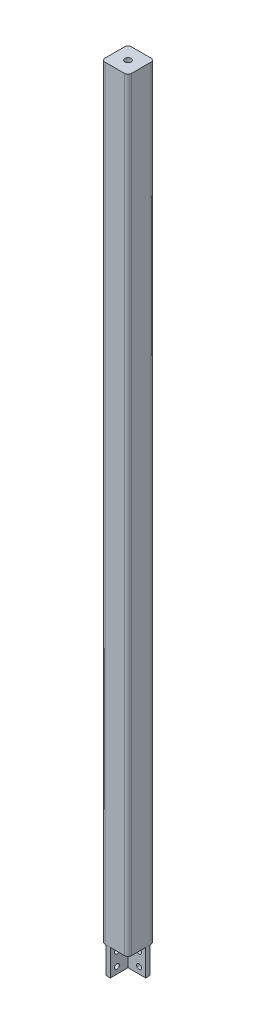
from build123d import *

# Parameters (mm, degrees)
F_60_X_60_X_4_0_1_DEPTH          = 1720
EXTRUDE_1_DEPTH                  = 10
HOLE_WIZARD_M16_1_D              = 14
EXTRUDE_4_DEPTH                  = 10
EXTRUDE_5_DEPTH                  = 60
SKETCH_22_W                      = 5.5
SKETCH_22_H                      = 50
HOLE_WIZARD_11_0_11_1_AT_2_COUNT = 2
HOLE_WIZARD_11_0_11_1_AT_2_PITCH = 30
SKETCH_24_W                      = 5.5
SKETCH_24_H                      = 20
HOLE_WIZARD_11_0_11_2_AT_2_COUNT = 2
HOLE_WIZARD_11_0_11_2_AT_2_PITCH = 30


with BuildPart() as part:
    # Sketch1 → 方管 60 X 60 X 4.0(1) (new body)
    with BuildSketch(Plane.XZ.offset(-1720)):
        with BuildLine():
            Line((-22, -30), (22, -30))
            ThreePointArc((22, -30), (27.656854249, -27.656854249), (30, -22))
            Line((30, -22), (30, 22))
            ThreePointArc((30, 22), (27.656854249, 27.656854249), (22, 30))
            Line((22, 30), (-22, 30))
            ThreePointArc((-22, 30), (-27.656854249, 27.656854249), (-30, 22))
            Line((-30, 22), (-30, -22))
            ThreePointArc((-30, -22), (-27.656854249, -27.656854249), (-22, -30))
        make_face()
        with BuildLine():
            Line((-22, -26), (22, -26))
            ThreePointArc((22, -26), (24.828427125, -24.828427125), (26, -22))
            Line((26, -22), (26, 22))
            ThreePointArc((26, 22), (24.828427125, 24.828427125), (22, 26))
            Line((22, 26), (-22, 26))
            ThreePointArc((-22, 26), (-24.828427125, 24.828427125), (-26, 22))
            Line((-26, 22), (-26, -22))
            ThreePointArc((-26, -22), (-24.828427125, -24.828427125), (-22, -26))
        make_face(mode=Mode.SUBTRACT)
    extrude(amount=F_60_X_60_X_4_0_1_DEPTH)

    # 草图4 → 凸台-拉伸1 (add)
    with BuildSketch(Plane(origin=(0, 1720, 0), x_dir=(1, 0, 0), z_dir=(0, 1, 0))):
        with BuildLine():
            Line((30, -22), (30, 22))
            ThreePointArc((30, 22), (27.656854249, 27.656854249), (22, 30))
            Line((22, 30), (-22, 30))
            ThreePointArc((-22, 30), (-27.656854249, 27.656854249), (-30, 22))
            Line((-30, 22), (-30, -22))
            ThreePointArc((-30, -22), (-27.656854249, -27.656854249), (-22, -30))
            Line((-22, -30), (22, -30))
            ThreePointArc((22, -30), (27.656854249, -27.656854249), (30, -22))
        make_face()
    extrude(amount=EXTRUDE_1_DEPTH)

    # M16 螺纹孔1 (through all)
    with Locations(Plane.ZX.offset(1730)):
        with Locations((0, 0)):
            Hole(HOLE_WIZARD_M16_1_D / 2)


with BuildPart() as body_2:
    # 草图15 → 凸台-拉伸4 (new body)
    with BuildSketch(Plane.XZ):
        with BuildLine():
            Line((-26, 22), (-26, -22))
            ThreePointArc((-26, -22), (-24.828427125, -24.828427125), (-22, -26))
            Line((-22, -26), (22, -26))
            ThreePointArc((22, -26), (24.828427125, -24.828427125), (26, -22))
            Line((26, -22), (26, 22))
            ThreePointArc((26, 22), (24.828427125, 24.828427125), (22, 26))
            Line((22, 26), (-22, 26))
            ThreePointArc((-22, 26), (-24.828427125, 24.828427125), (-26, 22))
        make_face()
    extrude(amount=-EXTRUDE_4_DEPTH)


with BuildPart() as body_3:
    # 草图19 → 凸台-拉伸5 (new body)
    with BuildSketch(Plane.XZ):
        Polygon((-20, 30), (-20, -20), (30, -20), (30, -10), (-10, -10), (-10, 30), align=None)
    extrude(amount=EXTRUDE_5_DEPTH)

    # 草图22 → Ø11.0 (11) 直径孔1 (revolve, cut)
    with BuildSketch(Plane(origin=(15, -15, -20), x_dir=(0, 1, 0), z_dir=(1, 0, 0))):
        with Locations((2.75, 25)):
            Rectangle(SKETCH_22_W, SKETCH_22_H)
    hole_wizard_11_0_11_1 = revolve(axis=Axis((15, -15, -26.35), (0, 0, 1)), mode=Mode.SUBTRACT)

    # Ø11.0 (11) 直径孔1 at 2: Ø11.0 (11) 直径孔1 ×2
    with Locations(*[(0, -i * HOLE_WIZARD_11_0_11_1_AT_2_PITCH, 0) for i in range(1, HOLE_WIZARD_11_0_11_1_AT_2_COUNT)]):
        add(hole_wizard_11_0_11_1, mode=Mode.SUBTRACT)

    # 草图24 → Ø11.0 (11) 直径孔2 (revolve, cut)
    with BuildSketch(Plane(origin=(-10, -45, 15), x_dir=(0, 0, -1), z_dir=(0, 1, 0))):
        with Locations((2.75, 10)):
            Rectangle(SKETCH_24_W, SKETCH_24_H)
    hole_wizard_11_0_11_2 = revolve(axis=Axis((-3.65, -45, 15), (-1, 0, 0)), mode=Mode.SUBTRACT)

    # Ø11.0 (11) 直径孔2 at 2: Ø11.0 (11) 直径孔2 ×2
    with Locations(*[(0, i * HOLE_WIZARD_11_0_11_2_AT_2_PITCH, 0) for i in range(1, HOLE_WIZARD_11_0_11_2_AT_2_COUNT)]):
        add(hole_wizard_11_0_11_2, mode=Mode.SUBTRACT)


solid = Compound([part.part, body_2.part, body_3.part])
